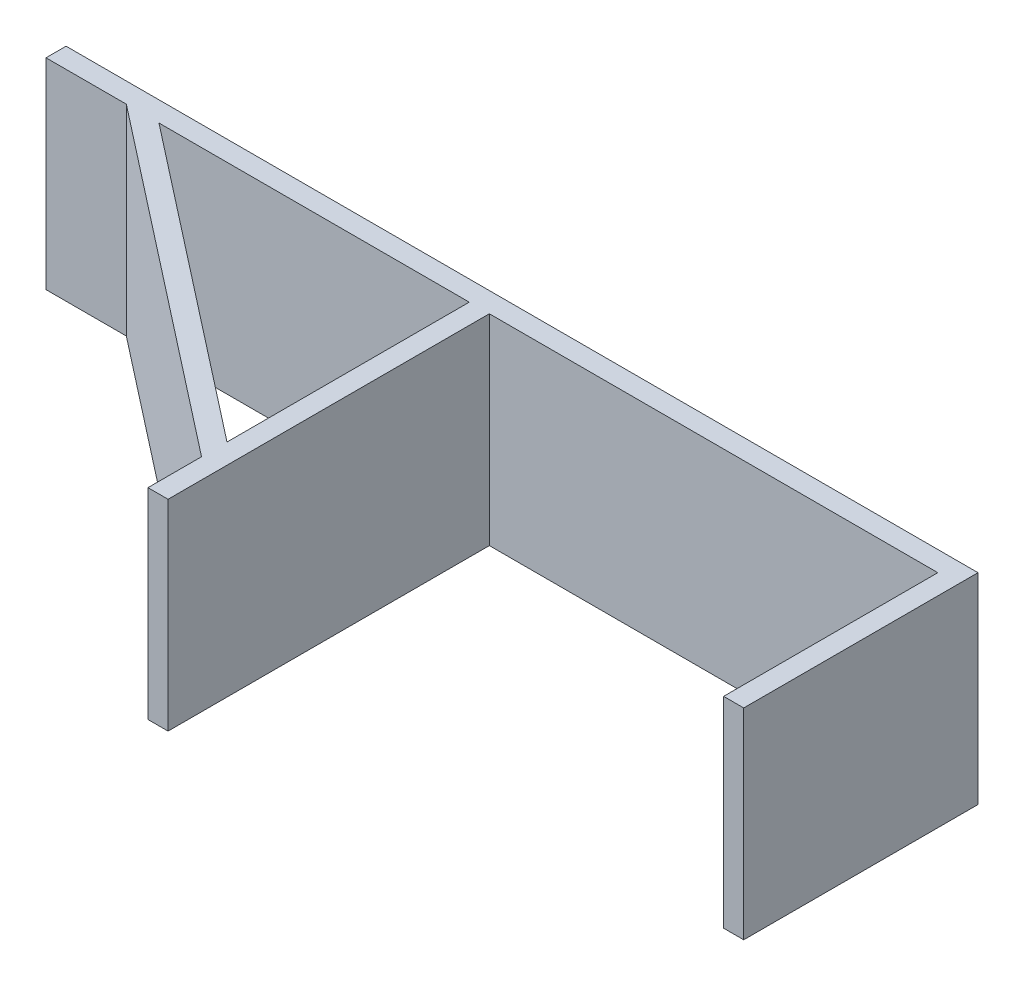
from build123d import *

# Parameters (mm, degrees)
BOSS_EXTRUDE2_DEPTH = 30
CUT_EXTRUDE1_DEPTH  = 30


with BuildPart() as part:
    # Sketch1 → Boss-Extrude2 (new body)
    with BuildSketch(Plane(origin=(0, 10, 0), x_dir=(1, 0, 0), z_dir=(0, 1, 0))):
        Polygon((71.5, -22), (71.5, 13), (-64.73475383, 13), (-64.73475383, 10), (-52.73475383, 10), (-1.5, -30), (-1.5, -38), (1.5, -38), (1.5, 10), (68.5, 10), (68.5, -22), align=None)
    extrude(amount=BOSS_EXTRUDE2_DEPTH)

    # Sketch4 → Cut-Extrude1 (cut)
    with BuildSketch(Plane.XZ.offset(-10)):
        Polygon((-47.85975383, -10), (-1.5, 26.193989716), (-1.5, -10), align=None)
    extrude(amount=-CUT_EXTRUDE1_DEPTH, mode=Mode.SUBTRACT)


solid = part.part
